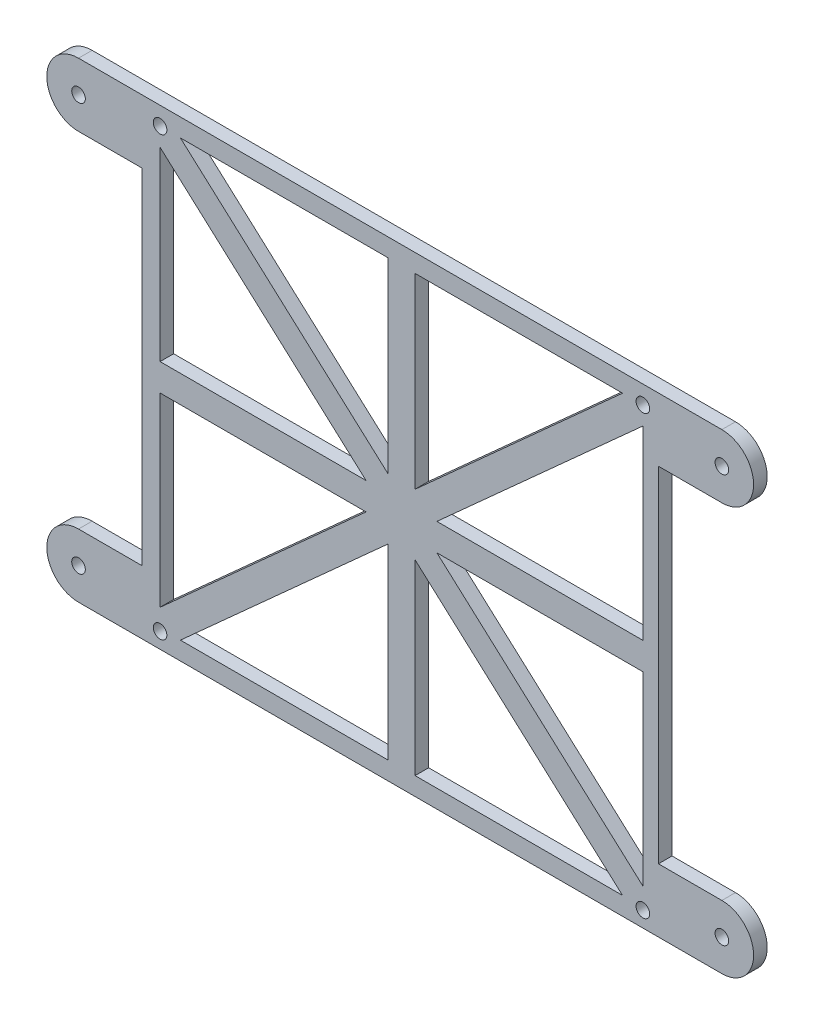
from build123d import *

# Parameters (mm, degrees)
SKETCH3_W                                  = 114
SKETCH3_H                                  = 104
BOSS_EXTRUDE1_DEPTH                        = 3
SKETCH4_R                                  = 1.5
CUT_EXTRUDE1_DEPTH                         = 78.21398837
LPATTERN1_COUNT                            = 2
LPATTERN1_PITCH                            = 106.56
LPATTERN1_COUNT_DIR2                       = 2
LPATTERN1_PITCH_DIR2                       = 96.56
BOSS_EXTRUDE2_DEPTH                        = 3
SKETCH6_R                                  = 1.5
CUT_EXTRUDE2_DEPTH                         = 94.79232378
MIRROR1_AT_THE_SECOND_PLANE_COPY_1_DEPTH   = 3
MIRROR1_AT_THE_SECOND_PLANE_COPY_2_SKETC_R = 1.5
MIRROR1_AT_THE_SECOND_PLANE_COPY_2_DEPTH   = 94.79232378
CUT_EXTRUDE3_DEPTH                         = 94.79232378


with BuildPart() as part:
    # Sketch3 → Boss-Extrude1 (new body)
    with BuildSketch(Plane.XY):
        Rectangle(SKETCH3_W, SKETCH3_H)
    extrude(amount=BOSS_EXTRUDE1_DEPTH)

    # Sketch4 → Cut-Extrude1 (cut, through all)
    with BuildSketch(Plane.XY.offset(3)):
        with Locations((-53, 48)):
            Circle(SKETCH4_R)
    cut_extrude1 = extrude(amount=-CUT_EXTRUDE1_DEPTH, mode=Mode.SUBTRACT)

    # LPattern1: Cut-Extrude1 2 × 2
    with Locations(*[(i * LPATTERN1_PITCH, -j * LPATTERN1_PITCH_DIR2, 0) for i in range(LPATTERN1_COUNT) for j in range(LPATTERN1_COUNT_DIR2) if (i, j) != (0, 0)]):
        add(cut_extrude1, mode=Mode.SUBTRACT)

    # Sketch5 → Boss-Extrude2 (add)
    with BuildSketch(Plane.XY.offset(3)):
        with BuildLine():
            Line((-57, 52), (-71, 52))
            ThreePointArc((-71, 52), (-78, 45), (-71, 38))
            Line((-71, 38), (-57, 38))
            Line((-57, 38), (-57, 52))
        make_face()
    boss_extrude2 = extrude(amount=-BOSS_EXTRUDE2_DEPTH)

    # Sketch6 → Cut-Extrude2 (cut, through all)
    with BuildSketch(Plane.XY.offset(3)):
        with Locations((-71, 45)):
            Circle(SKETCH6_R)
    cut_extrude2 = extrude(amount=-CUT_EXTRUDE2_DEPTH, mode=Mode.SUBTRACT)

    # Mirror1: Boss-Extrude2, Cut-Extrude2 across plane
    add(boss_extrude2.mirror(Plane.ZX))
    add(cut_extrude2.mirror(Plane.ZX), mode=Mode.SUBTRACT)

    # Mirror1 at the second plane: Boss-Extrude2, Cut-Extrude2 across plane
    add(boss_extrude2.mirror(Plane(origin=(0, 0, 0), x_dir=(0, 0, 1), z_dir=(1, 0, 0))))
    add(cut_extrude2.mirror(Plane(origin=(0, 0, 0), x_dir=(0, 0, 1), z_dir=(1, 0, 0))), mode=Mode.SUBTRACT)

    # Mirror1 at the second plane copy 1 sketc → Mirror1 at the second plane copy 1 (add)
    with BuildSketch(Plane(origin=(0, 0, 3), x_dir=(-1, 0, 0), z_dir=(0, 0, 1))):
        with BuildLine():
            Line((-57, 52), (-71, 52))
            ThreePointArc((-71, 52), (-78, 45), (-71, 38))
            Line((-71, 38), (-57, 38))
            Line((-57, 38), (-57, 52))
        make_face()
    extrude(amount=-MIRROR1_AT_THE_SECOND_PLANE_COPY_1_DEPTH)

    # Mirror1 at the second plane copy 2 sketc → Mirror1 at the second plane copy 2 (cut, through all)
    with BuildSketch(Plane(origin=(0, 0, 3), x_dir=(-1, 0, 0), z_dir=(0, 0, 1))):
        with Locations((-71, 45)):
            Circle(MIRROR1_AT_THE_SECOND_PLANE_COPY_2_SKETC_R)
    extrude(amount=-MIRROR1_AT_THE_SECOND_PLANE_COPY_2_DEPTH, mode=Mode.SUBTRACT)

    # Sketch7 → Cut-Extrude3 (cut, through all)
    with BuildSketch(Plane.XY.offset(3)):
        Polygon((-2.72, -48), (-2.72, -6.740598429), (-48.517935743, -48), align=None)
        Polygon((49.077935743, -48), (3.28, -6.740598429), (3.28, -48), align=None)
        Polygon((53.56, -3), (8.092064257, -3), (53.56, -43.962104273), align=None)
        Polygon((53.56, 43.962104273), (8.092064257, 3), (53.56, 3), align=None)
        Polygon((3.28, 48), (3.28, 6.740598429), (49.077935743, 48), align=None)
        Polygon((-48.517935743, 48), (-2.72, 6.740598429), (-2.72, 48), align=None)
        Polygon((-53, 43.962104273), (-53, 3), (-7.532064257, 3), align=None)
        Polygon((-7.532064257, -3), (-53, -3), (-53, -43.962104273), align=None)
    extrude(amount=-CUT_EXTRUDE3_DEPTH, mode=Mode.SUBTRACT)


solid = part.part
